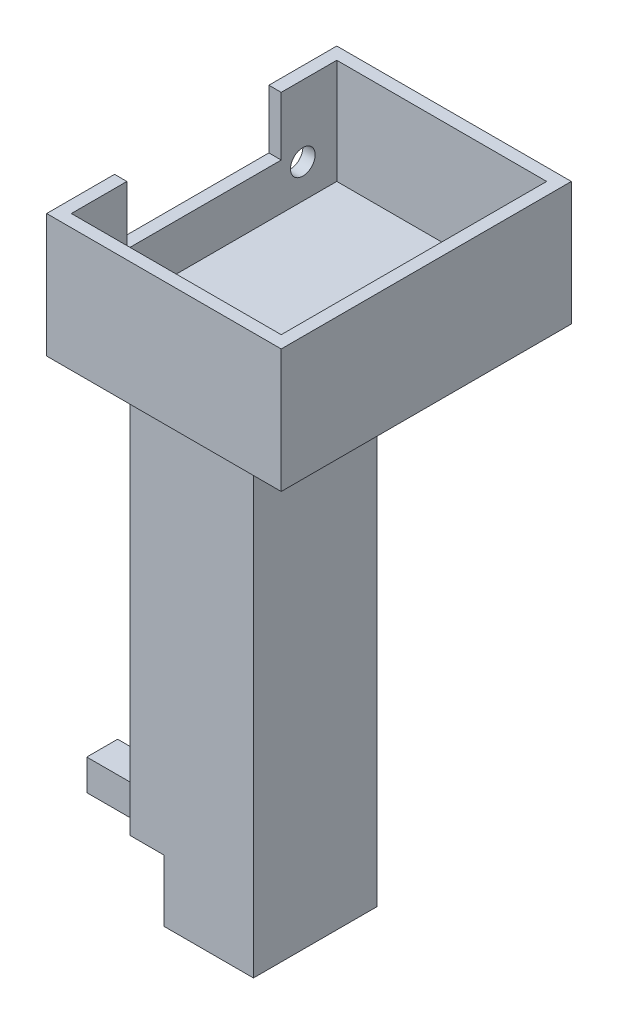
from build123d import *

# Parameters (mm, degrees)
SKETCH3_W            = 38
SKETCH3_H            = 47
SKETCH3_W_2          = 34
SKETCH3_H_2          = 43
BOSS_EXTRUDE4_DEPTH  = 10.5
SKETCH1_W            = 34
SKETCH1_H            = 43
BOSS_EXTRUDE5_DEPTH  = 3
BOSS_EXTRUDE6_DEPTH  = 9.5
CUT_EXTRUDE1_REACH   = 4
SKETCH6_R            = 2
SKETCH8_W            = 20
SKETCH8_H            = 20
BOSS_EXTRUDE7_DEPTH  = 84
CUT_EXTRUDE2_DEPTH   = 5.5
SKETCH12_W           = 5
SKETCH12_H           = 5
BOSS_EXTRUDE11_DEPTH = 14.5


with BuildPart() as part:
    # Sketch3 → Boss-Extrude4 (new body)
    with BuildSketch(Plane(origin=(0, 0, 0), x_dir=(1, 0, 0), z_dir=(0, 1, 0))):
        with Locations((31, 71.5)):
            Rectangle(SKETCH3_W, SKETCH3_H)
        with Locations((31, 71.5)):
            Rectangle(SKETCH3_W_2, SKETCH3_H_2, mode=Mode.SUBTRACT)
    extrude(amount=BOSS_EXTRUDE4_DEPTH)

    # Sketch1 → Boss-Extrude5 (add)
    with BuildSketch(Plane(origin=(0, 0, 0), x_dir=(1, 0, 0), z_dir=(0, 1, 0))):
        with Locations((31, 71.5)):
            Rectangle(SKETCH1_W, SKETCH1_H)
    extrude(amount=BOSS_EXTRUDE5_DEPTH)

    # Sketch7 → Boss-Extrude6 (add)
    with BuildSketch(Plane(origin=(0, 10.5, 0), x_dir=(1, 0, 0), z_dir=(0, 1, 0))):
        Polygon((14, 50), (14, 59), (12, 59), (12, 48), (50, 48), (50, 95), (12, 95), (12, 84), (14, 84), (14, 93), (48, 93), (48, 50), align=None)
    extrude(amount=BOSS_EXTRUDE6_DEPTH)

    # Sketch6 → Cut-Extrude1 (cut, up to next)
    with BuildSketch(Plane(origin=(14, 0, 0), x_dir=(0, 0, -1), z_dir=(1, 0, 0)), mode=Mode.PRIVATE) as cut_extrude1_sk1:
        with Locations((55.5, 8.5)):
            Circle(SKETCH6_R)
    cut_extrude1_tool1 = extrude(cut_extrude1_sk1.sketch, amount=-CUT_EXTRUDE1_REACH, mode=Mode.PRIVATE) & part.part
    add(cut_extrude1_tool1.solids().sort_by_distance((14, 8.5, -55.5))[0], mode=Mode.SUBTRACT)
    # Sketch6 → Cut-Extrude1 (cut, up to next)
    with BuildSketch(Plane(origin=(14, 0, 0), x_dir=(0, 0, -1), z_dir=(1, 0, 0)), mode=Mode.PRIVATE) as cut_extrude1_sk2:
        with Locations((87.5, 8.5)):
            Circle(SKETCH6_R)
    cut_extrude1_tool2 = extrude(cut_extrude1_sk2.sketch, amount=-CUT_EXTRUDE1_REACH, mode=Mode.PRIVATE) & part.part
    add(cut_extrude1_tool2.solids().sort_by_distance((14, 8.5, -87.5))[0], mode=Mode.SUBTRACT)

    # Sketch8 → Boss-Extrude7 (add)
    with BuildSketch(Plane.XZ):
        with Locations((22, -71.5)):
            Rectangle(SKETCH8_W, SKETCH8_H)
    extrude(amount=BOSS_EXTRUDE7_DEPTH)

    # Sketch11 → Cut-Extrude2 (cut)
    with BuildSketch(Plane.ZY.offset(-12)):
        Polygon((-74, -74), (-81.5, -74), (-81.5, -84), (-61.5, -84), (-61.5, -74), (-69, -74), (-69, -79), (-74, -79), align=None)
    extrude(amount=-CUT_EXTRUDE2_DEPTH, mode=Mode.SUBTRACT)

    # Sketch12 → Boss-Extrude11 (add)
    with BuildSketch(Plane.ZY.offset(-12)):
        with Locations((-71.5, -76.5)):
            Rectangle(SKETCH12_W, SKETCH12_H)
    extrude(amount=BOSS_EXTRUDE11_DEPTH)


solid = part.part
